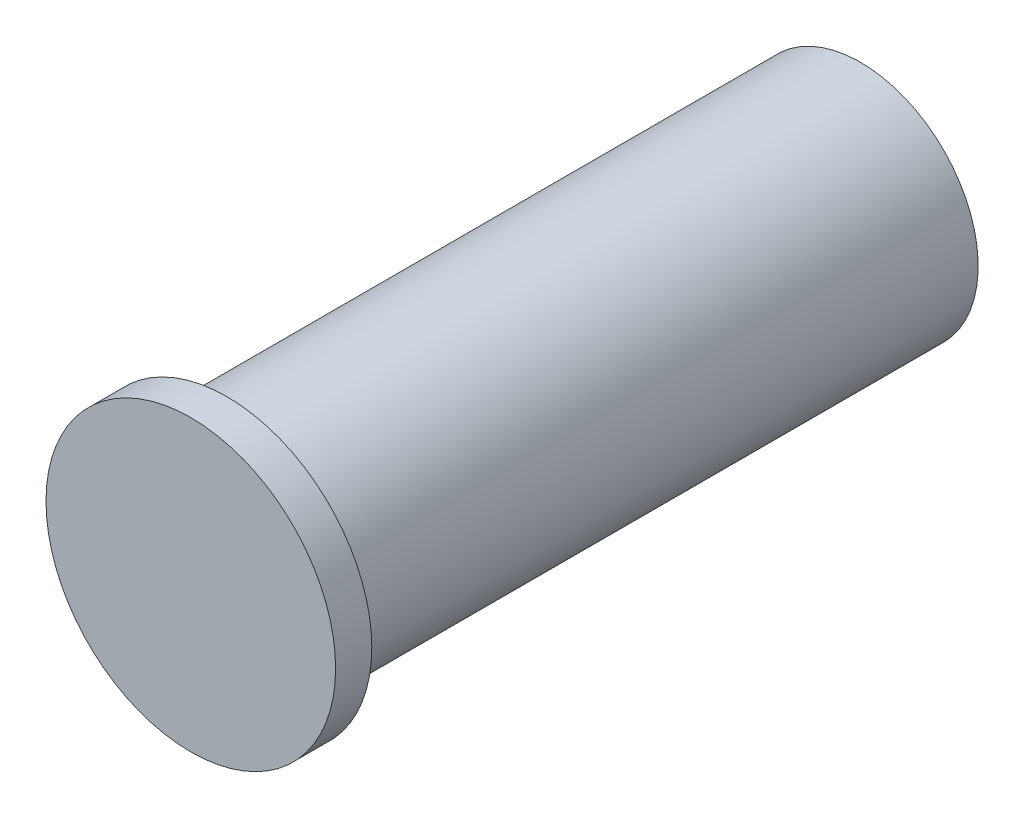
from build123d import *

# Parameters (mm, degrees)
SKETCH1_R           = 1.6
BOSS_EXTRUDE1_DEPTH = 0.4
SKETCH2_R           = 1.3
BOSS_EXTRUDE2_DEPTH = 7


with BuildPart() as part:
    # Sketch1 → Boss-Extrude1 (new body)
    with BuildSketch(Plane.XY):
        Circle(SKETCH1_R)
    extrude(amount=BOSS_EXTRUDE1_DEPTH)

    # Sketch2 → Boss-Extrude2 (add)
    with BuildSketch(Plane(origin=(0, 0, 0), x_dir=(-1, 0, 0), z_dir=(0, 0, -1))):
        Circle(SKETCH2_R)
    extrude(amount=BOSS_EXTRUDE2_DEPTH)


solid = part.part
